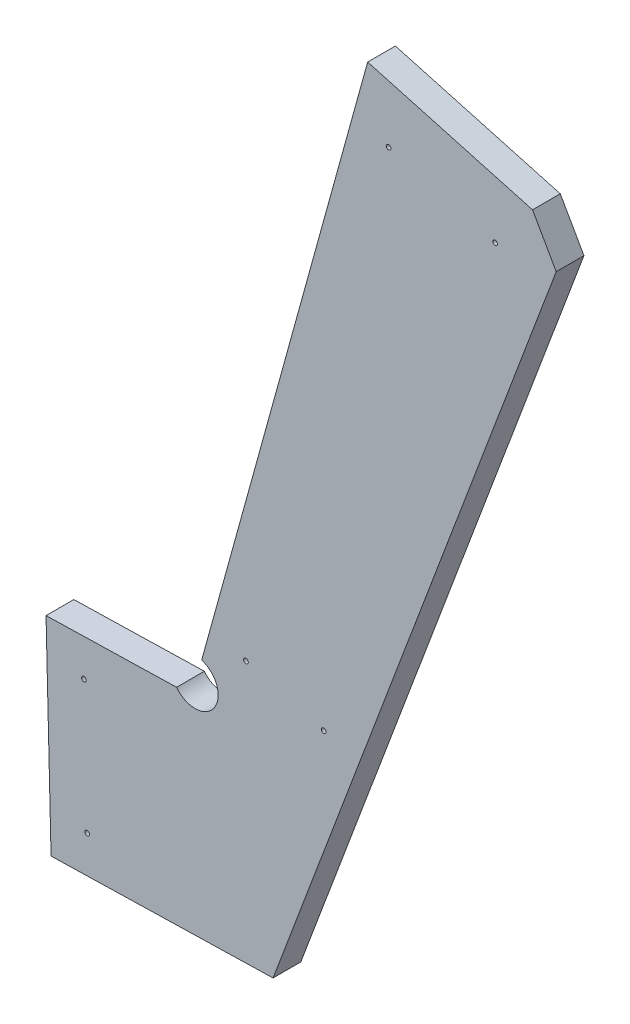
from build123d import *

# Parameters (mm, degrees)
BOSS_EXTRUDE1_DEPTH = 19.05
HOLE2_D             = 3.175
HOLE2_DEPTH         = 31.75
HOLE2_CSINK_D       = 10.16
HOLE2_CSINK_ANGLE   = 82
HOLE2_TIP           = 0.953866233
HOLE3_D             = 3.175
HOLE3_DEPTH         = 38.1
HOLE3_CSINK_D       = 10.16
HOLE3_CSINK_ANGLE   = 82
HOLE3_TIP           = 0.953866233


with BuildPart() as part:
    # Sketch1 → Boss-Extrude1 (new body)
    with BuildSketch(Plane.XY):
        with BuildLine():
            Line((-45.645654956, -462.283590669), (-42.196851456, -603.529354269))
            Line((-42.196851456, -603.529354269), (110.157739028, -599.809306096))
            Line((110.157739028, -599.809306096), (304.502022379, -82.799914861))
            Line((304.502022379, -82.799914861), (288.249001778, -54.142860136))
            Line((288.249001778, -54.142860136), (175.093421906, -22.889613201))
            Line((175.093421906, -22.889613201), (61.177817241, -435.332721236))
            ThreePointArc((61.177817241, -435.332721236), (69.660650717, -459.60790015), (43.950640658, -460.09591431))
            Line((43.950640658, -460.09591431), (-45.645654956, -462.283590669))
        make_face()
    extrude(amount=BOSS_EXTRUDE1_DEPTH)

    # Hole2
    with Locations(Plane(origin=(162.245907498, -21.702082459, 165.474999994), x_dir=(0, 0, -1), z_dir=(-0.963909776, 0.266229118, 0))):
        with Locations((-155.949999994, 107.734820482), (155.949999994, 107.734820482), (155.949999994, 327.755881328), (174.999999994, 85.732714397), (174.999999994, 349.757987412), (-174.999999994, 349.757987412), (-174.999999994, 85.732714397), (-155.949999994, 327.755881328)):
            CounterSinkHole(HOLE2_D / 2, HOLE2_CSINK_D / 2, depth=HOLE2_DEPTH, counter_sink_angle=HOLE2_CSINK_ANGLE)
            with Locations((0, 0, -(HOLE2_DEPTH + HOLE2_TIP / 2))):  # 118° drill point
                Cone(0, HOLE2_D / 2, HOLE2_TIP, mode=Mode.SUBTRACT)

    # Hole3
    with Locations(Plane(origin=(311.92831292, -63.043933951, -19.05), x_dir=(-0.351862635, -0.936051647, 0), z_dir=(0, 0, -1))):
        with Locations((46.221112845, 113.488854888), (39.39759596, 37.945520226), (412.28786892, 80.423559293), (407.308516105, 25.297013484), (513.561319184, 161.164706775), (597.46020397, 127.267357003), (610.543339245, 159.649253123), (694.322923815, 367.011001477), (526.644454459, 193.546602895), (610.424039029, 400.908351249)):
            CounterSinkHole(HOLE3_D / 2, HOLE3_CSINK_D / 2, depth=HOLE3_DEPTH, counter_sink_angle=HOLE3_CSINK_ANGLE)
            with Locations((0, 0, -(HOLE3_DEPTH + HOLE3_TIP / 2))):  # 118° drill point
                Cone(0, HOLE3_D / 2, HOLE3_TIP, mode=Mode.SUBTRACT)


solid = part.part
